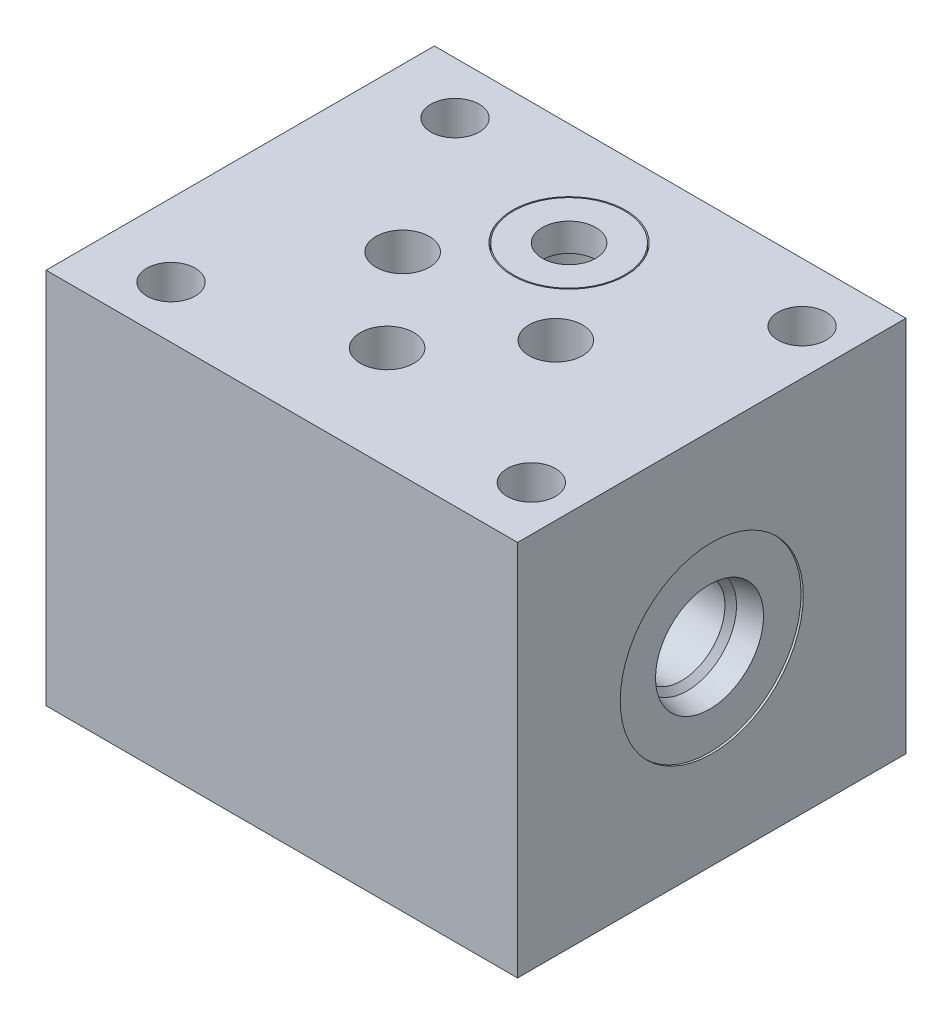
from build123d import *

# Parameters (mm, degrees)
SKETCH1_W          = 53.975
SKETCH1_H          = 44.45
EXTRUDE1_DEPTH     = 43.18
SKETCH2_R          = 3.0607
CUT_EXTRUDE1_DEPTH = 44.18
SKETCH3_R          = 5.5626
CUT_EXTRUDE2_DEPTH = 1.27
SKETCH4_R          = 0.889
SKETCH5_R          = 0.889
SKETCH6_R          = 0.889
SKETCH7_R          = 0.889
SKETCH16_R         = 6.4897
CUT_EXTRUDE3_DEPTH = 3.2004
SKETCH17_R         = 5.7785
CUT_EXTRUDE4_DEPTH = 17.6784
SKETCH13_R         = 6.35
SKETCH13_R_2       = 3.0607
EXTRUDE2_DEPTH     = 3.2004
SKETCH18_W         = 2.7686
SKETCH18_H         = 43.18
HOLE1_AT_2_COUNT   = 2
HOLE1_AT_2_PITCH   = 40.494770005
HOLE1_AT_3_COUNT   = 2
HOLE1_AT_3_PITCH   = 51.451999512
HOLE1_AT_4_COUNT   = 2
HOLE1_AT_4_PITCH   = 30.988


with BuildPart() as part:
    # Sketch1 → Extrude1 (new body)
    with BuildSketch(Plane(origin=(0, 0, 0), x_dir=(1, 0, 0), z_dir=(0, 1, 0))):
        Rectangle(SKETCH1_W, SKETCH1_H)
    extrude(amount=EXTRUDE1_DEPTH)

    # Sketch2 → Cut-Extrude1 (cut, through all)
    with BuildSketch(Plane(origin=(0, 43.18, 0), x_dir=(-1, 0, 0), z_dir=(0, 1, 0))):
        with Locations(Location((-0.2413, 10.414, 0), (0, 0, 90))):  # turned: the seam where the file's is
            Circle(SKETCH2_R)
        with Locations(Location((-0.2413, -10.414, 0), (0, 0, 90))):  # turned: the seam where the file's is
            Circle(SKETCH2_R)
        with Locations(Location((-9.1313, 0, 0), (0, 0, 90))):  # turned: the seam where the file's is
            Circle(SKETCH2_R)
        with Locations(Location((8.3947, 0, 0), (0, 0, 90))):  # turned: the seam where the file's is
            Circle(SKETCH2_R)
    extrude(amount=-CUT_EXTRUDE1_DEPTH, mode=Mode.SUBTRACT)

    # Sketch3 → Cut-Extrude2 (cut)
    with BuildSketch(Plane.XZ):
        with Locations(Location((0.2413, -10.414, 0), (0, 0, 270))):  # turned: the seam where the file's is
            Circle(SKETCH3_R)
        with Locations(Location((9.1313, 0, 0), (0, 0, 270))):  # turned: the seam where the file's is
            Circle(SKETCH3_R)
        with Locations(Location((0.2413, 10.414, 0), (0, 0, 270))):  # turned: the seam where the file's is
            Circle(SKETCH3_R)
        with Locations(Location((-8.3947, 0, 0), (0, 0, 270))):  # turned: the seam where the file's is
            Circle(SKETCH3_R)
    extrude(amount=-CUT_EXTRUDE2_DEPTH, mode=Mode.SUBTRACT)

    # S2D0007 → Cut-Revolve1 (revolve, cut)
    with BuildSketch(Plane(origin=(26.9875, 21.59, 0), x_dir=(0, -1, 0), z_dir=(0, 0, 1)), mode=Mode.PRIVATE) as cut_revolve1_sk:
        Polygon((0, 0), (10.4775, 0), (10.4775, -0.254), (6.1849, -0.254), (5.642306865, -2.8067), (4.9784, -3.470606865), (4.9784, -14.224), (0, -14.224), align=None)
    revolve(cut_revolve1_sk.sketch.rotate(Axis((5.060825477, 21.59, 0), (1, 0, 0)), 270), axis=Axis((5.060825477, 21.59, 0), (1, 0, 0)), mode=Mode.SUBTRACT)  # turned: the seam where the file's is

    # Sketch9 → Cut-Revolve2 (revolve, cut)
    with BuildSketch(Plane(origin=(-26.9875, 21.59, 0), x_dir=(0, 1, 0), z_dir=(0, 0, 1)), mode=Mode.PRIVATE) as cut_revolve2_sk:
        Polygon((0, 0), (10.4775, 0), (10.4775, -0.254), (6.1849, -0.254), (5.642306865, -2.8067), (4.9784, -3.470606865), (4.9784, -14.224), (0, -14.224), align=None)
    revolve(cut_revolve2_sk.sketch.rotate(Axis((-12.0523, 21.59, 0), (-1, 0, 0)), 270), axis=Axis((-12.0523, 21.59, 0), (-1, 0, 0)), mode=Mode.SUBTRACT)  # turned: the seam where the file's is

    # S2D0006 → Cut-Revolve3 (revolve, cut)
    with BuildSketch(Plane(origin=(26.9875, 21.59, 0), x_dir=(0, -1, 0), z_dir=(0, 0, 1)), mode=Mode.PRIVATE) as cut_revolve3_sk:
        Polygon((0, 0), (2.1844, 0), (2.1844, -17.8562), (0, -19.168719936), align=None)
    revolve(cut_revolve3_sk.sketch.rotate(Axis((6.860344067, 21.59, 0), (1, 0, 0)), 270), axis=Axis((6.860344067, 21.59, 0), (1, 0, 0)), mode=Mode.SUBTRACT)  # turned: the seam where the file's is

    # Sketch11 → Cut-Revolve4 (revolve, cut)
    with BuildSketch(Plane(origin=(-26.9875, 21.59, 0), x_dir=(0, 1, 0), z_dir=(0, 0, 1)), mode=Mode.PRIVATE) as cut_revolve4_sk:
        Polygon((0, 0), (2.1844, 0), (2.1844, -15.4178), (0, -16.730319936), align=None)
    revolve(cut_revolve4_sk.sketch.rotate(Axis((-9.420664067, 21.59, 0), (-1, 0, 0)), 143.124768154), axis=Axis((-9.420664067, 21.59, 0), (-1, 0, 0)), mode=Mode.SUBTRACT)  # turned: the seam where the file's is

    # Sketch16 → Cut-Extrude3 (cut)
    with BuildSketch(Plane(origin=(0, 43.18, 0), x_dir=(1, 0, 0), z_dir=(0, 1, 0))):
        with Locations(Location((0.2413, 10.414, 0), (0, 0, 270))):  # turned: the seam where the file's is
            Circle(SKETCH16_R)
    extrude(amount=-CUT_EXTRUDE3_DEPTH, mode=Mode.SUBTRACT)

    # Sketch17 → Cut-Extrude4 (cut)
    with BuildSketch(Plane(origin=(0, 43.18, 0), x_dir=(1, 0, 0), z_dir=(0, 1, 0))):
        with Locations(Location((0.2413, 10.414, 0), (0, 0, 270))):  # turned: the seam where the file's is
            Circle(SKETCH17_R)
    extrude(amount=-CUT_EXTRUDE4_DEPTH, mode=Mode.SUBTRACT)

    # Sketch13 → Extrude2 (add)
    with BuildSketch(Plane(origin=(0, 43.18, 0), x_dir=(-1, 0, 0), z_dir=(0, 1, 0))):
        with Locations(Location((-0.2413, -10.414, 0), (0, 0, 90))):  # turned: the seam where the file's is
            Circle(SKETCH13_R)
        with Locations(Location((-0.2413, -10.414, 0), (0, 0, 90))):  # turned: the seam where the file's is
            Circle(SKETCH13_R_2, mode=Mode.SUBTRACT)
    extrude(amount=-EXTRUDE2_DEPTH)

    # Sketch18 → Hole1 (revolve, cut)
    with BuildSketch(Plane(origin=(21.8313, 0, 15.494), x_dir=(0, 0, -1), z_dir=(1, 0, 0))):
        with Locations((1.3843, 21.59)):
            Rectangle(SKETCH18_W, SKETCH18_H)
    hole1 = revolve(axis=Axis((21.8313, 110, 15.494), (0, -1, 0)), mode=Mode.SUBTRACT)

    # Hole1 at 2: Hole1 ×2
    with Locations(*[Vector(-0.99982294, 0, 0.018817245) * (i * HOLE1_AT_2_PITCH) for i in range(1, HOLE1_AT_2_COUNT)]):
        add(hole1, mode=Mode.SUBTRACT)

    # Hole1 at 3: Hole1 ×2
    with Locations(*[Vector(-0.78690042, 0, -0.617080003) * (i * HOLE1_AT_3_PITCH) for i in range(1, HOLE1_AT_3_COUNT)]):
        add(hole1, mode=Mode.SUBTRACT)

    # Hole1 at 4: Hole1 ×2
    with Locations(*[(0, 0, -i * HOLE1_AT_4_PITCH) for i in range(1, HOLE1_AT_4_COUNT)]):
        add(hole1, mode=Mode.SUBTRACT)


with BuildPart() as body_2:
    # Sketch4 → Revolve1 (revolve)
    with BuildSketch(Plane(origin=(0.2413, 1.27, -10.414), x_dir=(1, 0, 0), z_dir=(0, 0, 1)), mode=Mode.PRIVATE) as revolve1_sk:
        with Locations((4.6736, -0.889)):
            Circle(SKETCH4_R)
    revolve(revolve1_sk.sketch.rotate(Axis((0.2413, -0.5969, -10.414), (0, 1, 0)), 90), axis=Axis((0.2413, -0.5969, -10.414), (0, 1, 0)))  # turned: the seam where the file's is


with BuildPart() as body_3:
    # Sketch5 → Revolve2 (revolve)
    with BuildSketch(Plane(origin=(9.1313, 1.27, 0), x_dir=(1, 0, 0), z_dir=(0, 0, 1)), mode=Mode.PRIVATE) as revolve2_sk:
        with Locations((4.6736, -0.889)):
            Circle(SKETCH5_R)
    revolve(revolve2_sk.sketch.rotate(Axis((9.1313, -0.5969, 0), (0, 1, 0)), 90), axis=Axis((9.1313, -0.5969, 0), (0, 1, 0)))  # turned: the seam where the file's is


with BuildPart() as body_4:
    # Sketch6 → Revolve3 (revolve)
    with BuildSketch(Plane(origin=(0.2413, 1.27, 10.414), x_dir=(1, 0, 0), z_dir=(0, 0, 1)), mode=Mode.PRIVATE) as revolve3_sk:
        with Locations((4.6736, -0.889)):
            Circle(SKETCH6_R)
    revolve(revolve3_sk.sketch.rotate(Axis((0.2413, -0.5969, 10.414), (0, 1, 0)), 90), axis=Axis((0.2413, -0.5969, 10.414), (0, 1, 0)))  # turned: the seam where the file's is


with BuildPart() as body_5:
    # Sketch7 → Revolve4 (revolve)
    with BuildSketch(Plane(origin=(-8.3947, 1.27, 0), x_dir=(1, 0, 0), z_dir=(0, 0, 1)), mode=Mode.PRIVATE) as revolve4_sk:
        with Locations((4.6736, -0.889)):
            Circle(SKETCH7_R)
    revolve(revolve4_sk.sketch.rotate(Axis((-8.3947, -0.5969, 0), (0, 1, 0)), 90), axis=Axis((-8.3947, -0.5969, 0), (0, 1, 0)))  # turned: the seam where the file's is


with BuildPart() as body_6:
    # Sketch12 → Revolve5 (revolve)
    with BuildSketch(Plane(origin=(0.2413, 1.27, -10.414), x_dir=(1, 0, 0), z_dir=(0, 0, 1))):
        with BuildLine():
            Line((0, 23.117869897), (0, 32.642869897))
            ThreePointArc((0, 32.642869897), (4.7625, 27.880369897), (0, 23.117869897))
        make_face()
    revolve(axis=Axis((0.2413, 23.911619897, -10.414), (0, 1, 0)))


solid = Compound([part.part, body_2.part, body_3.part, body_4.part, body_5.part, body_6.part])
